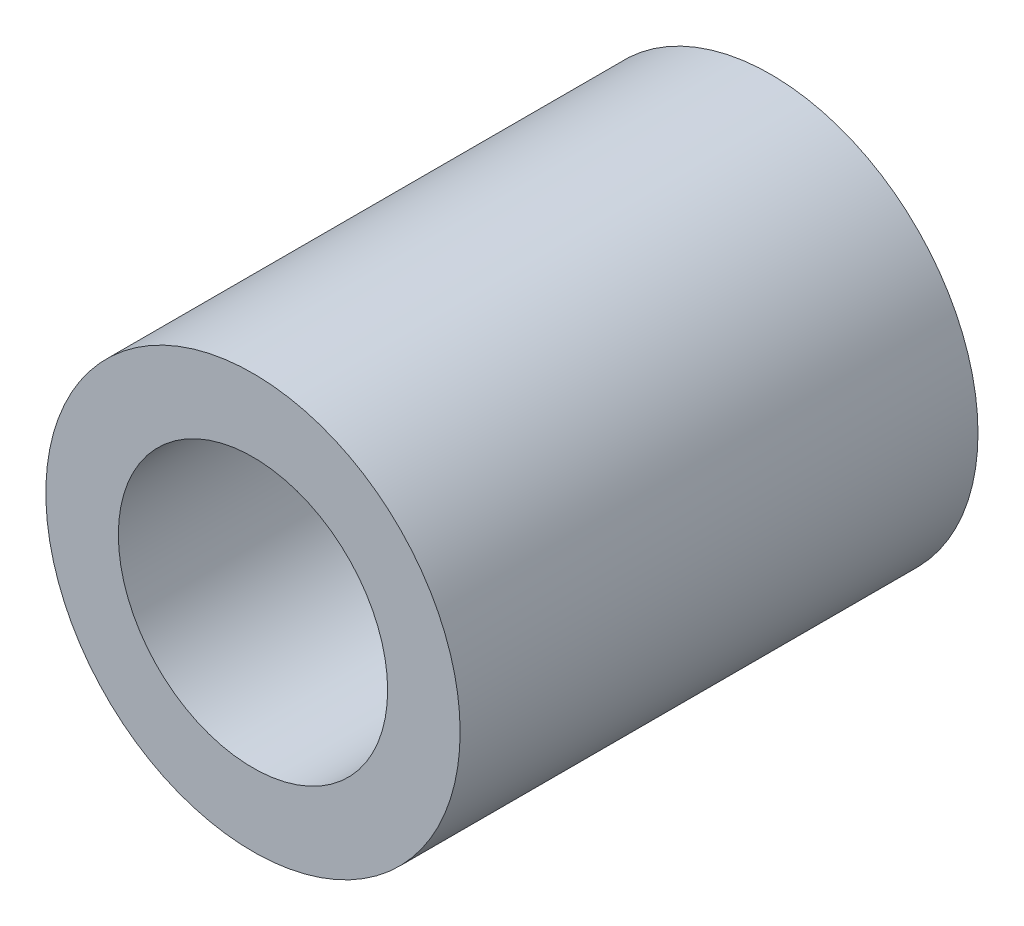
from build123d import *

# Parameters (mm, degrees)
SKETCH1_R           = 2
BOSS_EXTRUDE1_DEPTH = 5
SKETCH2_R           = 1.3
CUT_EXTRUDE1_DEPTH  = 6


with BuildPart() as part:
    # Sketch1 → Boss-Extrude1 (new body)
    with BuildSketch(Plane.XY):
        Circle(SKETCH1_R)
    extrude(amount=-BOSS_EXTRUDE1_DEPTH)

    # Sketch2 → Cut-Extrude1 (cut, through all)
    with BuildSketch(Plane.XY):
        Circle(SKETCH2_R)
    extrude(amount=-CUT_EXTRUDE1_DEPTH, mode=Mode.SUBTRACT)


solid = part.part
